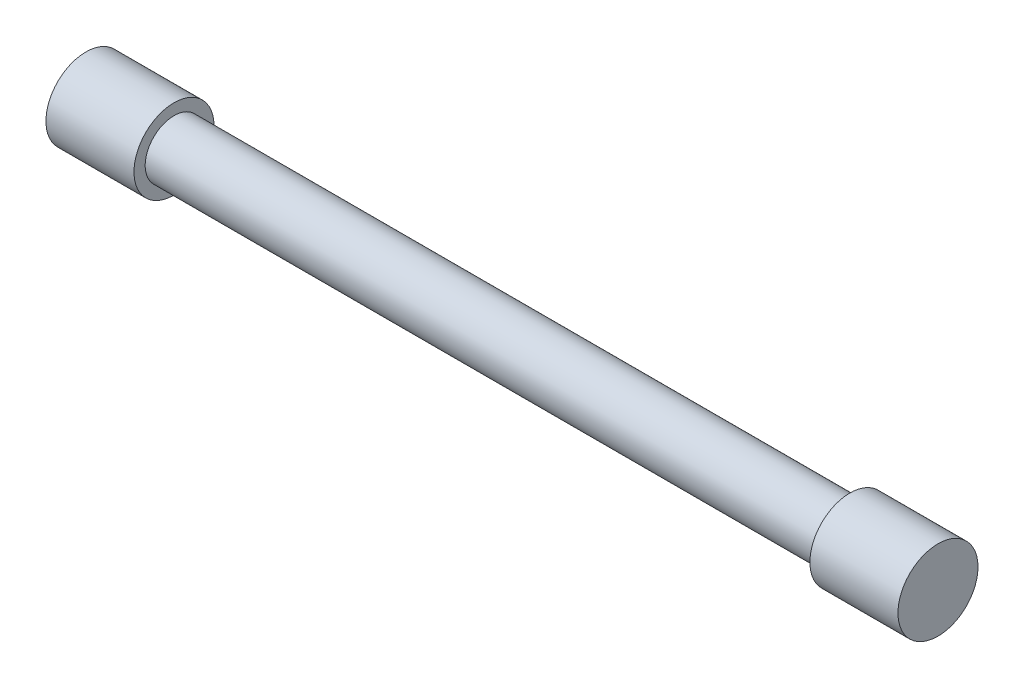
from build123d import *

# Parameters (mm, degrees)
SKETCH1_R           = 12.5
SKETCH1_R_2         = 9
BOSS_EXTRUDE1_DEPTH = 27.5
SKETCH1_3_R         = 9
BOSS_EXTRUDE2_DEPTH = 266.1
BOSS_EXTRUDE3_START = -27.5
SKETCH2_R           = 12.5
BOSS_EXTRUDE3_DEPTH = 27.5


with BuildPart() as part:
    # Sketch1 → Boss-Extrude1 (new body)
    with BuildSketch(Plane(origin=(0, 0, 0), x_dir=(0, 0, -1), z_dir=(1, 0, 0))):
        Circle(SKETCH1_R)
        Circle(SKETCH1_R_2, mode=Mode.SUBTRACT)
    extrude(amount=BOSS_EXTRUDE1_DEPTH)

    # Sketch1_3 → Boss-Extrude2 (add)
    with BuildSketch(Plane(origin=(0, 0, 0), x_dir=(0, 0, -1), z_dir=(1, 0, 0))):
        Circle(SKETCH1_3_R)
    extrude(amount=BOSS_EXTRUDE2_DEPTH)

    # Sketch2 → Boss-Extrude3 (add)
    with BuildSketch(Plane(origin=(266.1, 0, 0), x_dir=(0, 0, -1), z_dir=(1, 0, 0)).offset(BOSS_EXTRUDE3_START)):
        Circle(SKETCH2_R)
    extrude(amount=BOSS_EXTRUDE3_DEPTH)


solid = part.part
